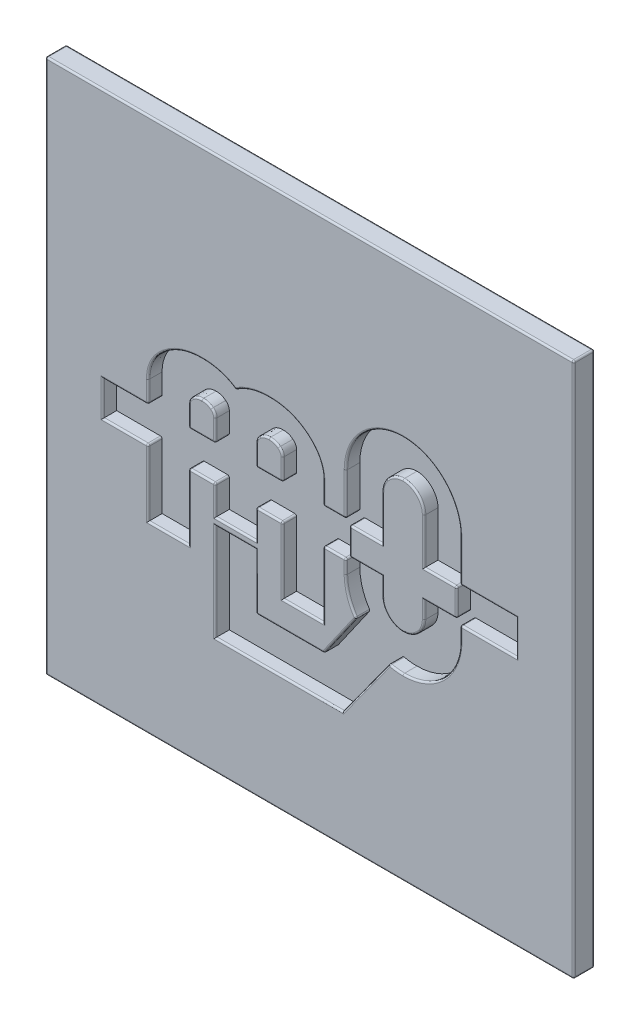
from build123d import *

# Parameters (mm, degrees)
ESBO_O4_W                = 75.8
ESBO_O4_H                = 76.8
RESSALTO_EXTRUS_O6_DEPTH = 1
ESBO_O2_W                = 75.8
ESBO_O2_H                = 76.8
RESSALTO_EXTRUS_O1_DEPTH = 3
FILETE1_R                = 0.25


with BuildPart() as part:
    # Esboço4 → Ressalto-extrusão6 (new body)
    with BuildSketch(Plane.XY):
        with Locations((33.383805964, -31.34946211)):
            Rectangle(ESBO_O4_W, ESBO_O4_H)
    extrude(amount=RESSALTO_EXTRUS_O6_DEPTH)

    # Esboço2 → Ressalto-extrusão1 (add)
    with BuildSketch(Plane.XY):
        with Locations((33.383805964, -31.34946211)):
            Rectangle(ESBO_O2_W, ESBO_O2_H)
        with BuildLine():
            Line((38.602792411, -35.840951316), (38.602792411, -33.838491955))
            Line((38.602792411, -33.838491955), (35.339621204, -33.838491955))
            Line((35.339621204, -33.838491955), (35.339621204, -43.373197244))
            Line((35.339621204, -43.373197244), (29.53003996, -43.373197244))
            Line((29.53003996, -43.373197244), (29.53003996, -33.83853704))
            Line((29.53003996, -33.83853704), (25.700089136, -33.838882375))
            Line((25.700089136, -33.838882375), (25.699216045, -38.027742975))
            Line((25.699216045, -38.027742975), (19.871317632, -38.027742975))
            Line((19.871317632, -38.027742975), (19.870691064, -33.838882374))
            Line((19.870691064, -33.838882374), (16.040555361, -33.838537038))
            Line((16.040555361, -33.838537038), (16.040555361, -43.373197244))
            Line((16.040555361, -43.373197244), (10.230941894, -43.373197244))
            Line((10.230941894, -43.373197244), (10.230941894, -33.838491955))
            Line((10.230941894, -33.838491955), (3.71082044, -33.838491955))
            Line((3.71082044, -33.838491955), (3.71082044, -28.860432264))
            Line((3.71082044, -28.860432264), (10.230941894, -28.860432264))
            Line((10.230941894, -28.860432264), (10.230941894, -25.767762916))
            add(Edge.make_bspline(
                [(12.520125537, -21.186846618), (12.161589327, -21.481361149), (11.478508088, -22.151017985), (10.765077158, -23.243042596), (10.326009571, -24.448263357), (10.230941894, -25.331943998), (10.230941894, -25.767762916)],
                knots=[3.999994529, 3.999994529, 3.999994529, 3.999994529, 4.249995897, 4.499997265, 4.749998632, 5, 5, 5, 5], degree=3))
            add(Edge.make_bspline(
                [(17.966484449, -19.325726975), (17.457089512, -19.325726975), (16.418731118, -19.402059073), (15.004785579, -19.750970723), (13.693531195, -20.3320269), (12.891893247, -20.881537531), (12.520125537, -21.186846618)],
                knots=[3, 3, 3, 3, 3.250001355, 3.50000271, 3.750004065, 4.00000542, 4.00000542, 4.00000542, 4.00000542], degree=3))
            add(Edge.make_bspline(
                [(22.777352151, -20.730420899), (22.435136603, -20.497769563), (21.71308317, -20.08499804), (20.546604604, -19.646084252), (19.306248733, -19.383399999), (18.408088538, -19.325726975), (17.966484449, -19.325726975)],
                knots=[2.068141729, 2.068141729, 2.068141729, 2.068141729, 2.301106297, 2.534070865, 2.767035432, 3, 3, 3, 3], degree=3))
            add(Edge.make_bspline(
                [(27.604143095, -19.325726975), (27.162098632, -19.325726975), (26.263453928, -19.383444504), (25.019999122, -19.646269008), (23.848951729, -20.085148911), (23.122077466, -20.497966794), (22.777352151, -20.730420899)],
                knots=[1, 1, 1, 1, 1.233058408, 1.466116815, 1.699175223, 1.932233631, 1.932233631, 1.932233631, 1.932233631], degree=3))
            add(Edge.make_bspline(
                [(33.0398984, -21.178917863), (32.669738598, -20.874624758), (31.871479625, -20.32757249), (30.563132067, -19.748947369), (29.151234418, -19.401694181), (28.113219244, -19.325726975), (27.604143095, -19.325726975)],
                knots=[3.9919e-05, 3.9919e-05, 3.9919e-05, 3.9919e-05, 0.250029939, 0.500019959, 0.75000998, 1, 1, 1, 1], degree=3))
            add(Edge.make_bspline(
                [(35.339621204, -25.767762916), (35.339621204, -25.331660129), (35.244187559, -24.447688229), (34.803194529, -23.240737978), (34.086701119, -22.146569866), (33.400046511, -21.474453552), (33.0398984, -21.178917863)],
                knots=[22, 22, 22, 22, 22.24999003, 22.49998006, 22.749970091, 22.999960121, 22.999960121, 22.999960121, 22.999960121], degree=3))
            Line((35.339621204, -25.767762916), (35.339621204, -28.860432264))
            Line((35.339621204, -28.860432264), (38.602792411, -28.860432264))
            Line((38.602792411, -28.860432264), (38.602792411, -22.842920896))
            add(Edge.make_bspline(
                [(46.797613273, -14.645489949), (46.246180807, -14.645489949), (45.128374456, -14.76083346), (43.080307896, -15.408787825), (40.869208073, -16.912223198), (39.366010859, -19.123952386), (38.718128317, -21.172814358), (38.602792411, -22.291217691), (38.602792411, -22.842920896)],
                knots=[0, 0, 0, 0, 0.125, 0.25, 0.5, 0.75, 0.875, 1, 1, 1, 1], degree=3))
            add(Edge.make_bspline(
                [(54.99504422, -22.842920896), (54.99504422, -22.291266213), (54.879896849, -21.172953621), (54.232788183, -19.124135909), (52.730639152, -16.912256195), (50.519086668, -15.408719739), (48.469348564, -14.760807883), (47.34979744, -14.645489949), (46.797613273, -14.645489949)],
                knots=[9, 9, 9, 9, 9.125, 9.25, 9.5, 9.75, 9.875, 10, 10, 10, 10], degree=3))
            Line((54.99504422, -22.842920896), (54.99504422, -28.860432264))
            Line((54.99504422, -28.860432264), (63.056791489, -28.860432264))
            Line((63.056791489, -28.860432264), (63.056791489, -33.838491955))
            Line((63.056791489, -33.838491955), (54.99504422, -33.838491955))
            Line((54.99504422, -33.838491955), (54.99504422, -35.840951316))
            add(Edge.make_bspline(
                [(54.778405418, -37.700723526), (54.814396652, -37.550265426), (54.877291352, -37.247758745), (54.945118138, -36.785428618), (54.98593037, -36.317198702), (54.99504422, -35.99928574), (54.99504422, -35.840951316)],
                knots=[12.00085461, 12.00085461, 12.00085461, 12.00085461, 12.250640957, 12.500427305, 12.750213652, 13, 13, 13, 13], degree=3))
            add(Edge.make_bspline(
                [(46.797613273, -44.038414486), (47.272657444, -44.038414486), (48.234123656, -43.953528144), (50.022954031, -43.472675095), (52.019859246, -42.338480082), (53.839600794, -40.314868095), (54.571707331, -38.588043624), (54.778405418, -37.700723526)],
                knots=[11, 11, 11, 11, 11.124982294, 11.249964588, 11.499929176, 11.749893764, 11.999858353, 11.999858353, 11.999858353, 11.999858353], degree=3))
            add(Edge.make_bspline(
                [(44.824204036, -43.795232726), (44.983014121, -43.835039775), (45.302141963, -43.904918132), (45.792159443, -43.981327313), (46.289665386, -44.027859613), (46.62884194, -44.038414486), (46.797613273, -44.038414486)],
                knots=[10.154565866, 10.154565866, 10.154565866, 10.154565866, 10.365924399, 10.577282933, 10.788641466, 11, 11, 11, 11], degree=3))
            Line((44.824204036, -43.795232726), (38.148867116, -53.002999655))
            Line((38.148867116, -53.002999655), (19.871242848, -53.000243488))
            Line((19.871242848, -53.000243488), (19.871242848, -39.094640358))
            Line((19.871242848, -39.094640358), (25.688751016, -39.094640358))
            Line((25.688751016, -39.094640358), (25.688751016, -47.11417514))
            Line((25.688751016, -47.11417514), (35.455669788, -47.11417514))
            Line((35.455669788, -47.11417514), (40.074399539, -40.514566147))
            add(Edge.make_bspline(
                [(38.602792411, -35.840951316), (38.602792411, -36.266635892), (38.670782886, -37.126960153), (38.96176903, -38.340427671), (39.42705098, -39.483596521), (39.842011377, -40.181929217), (40.074399539, -40.514566147)],
                knots=[8, 8, 8, 8, 8.232321709, 8.464643418, 8.696965127, 8.929286836, 8.929286836, 8.929286836, 8.929286836], degree=3))
        make_face(mode=Mode.SUBTRACT)
        with BuildLine():
            Line((43.78038713, -29.360432264), (39.102792411, -29.360432264))
            Line((39.102792411, -29.360432264), (39.102792411, -33.338491955))
            Line((39.102792411, -33.338491955), (43.78038713, -33.338491955))
            Line((43.78038713, -33.338491955), (43.78038713, -35.840951316))
            add(Edge.make_bspline(
                [(43.78038713, -35.840951316), (43.78038713, -35.917513812), (43.783029438, -35.999360925), (43.790956363, -36.075891198)],
                knots=[4, 4, 4, 4, 5, 5, 5, 5], degree=3))
            add(Edge.make_bspline(
                [(43.790956363, -36.075891198), (43.915015963, -37.609590087), (45.240165832, -38.860819768), (46.797613273, -38.860819768)],
                knots=[3, 3, 3, 3, 4, 4, 4, 4], degree=3))
            add(Edge.make_bspline(
                [(46.797613273, -38.860819768), (47.209394476, -38.860819768), (47.605354051, -38.773720262), (47.964353533, -38.615310653)],
                knots=[2, 2, 2, 2, 3, 3, 3, 3], degree=3))
            add(Edge.make_bspline(
                [(47.964353533, -38.615310653), (48.476478007, -38.396224622), (48.917324601, -38.034582832), (49.242006297, -37.585841535)],
                knots=[1, 1, 1, 1, 2, 2, 2, 2], degree=3))
            add(Edge.make_bspline(
                [(49.242006297, -37.585841535), (49.603615864, -37.092180997), (49.817449502, -36.487704623), (49.817449502, -35.840951316)],
                knots=[0, 0, 0, 0, 1, 1, 1, 1], degree=3))
            Line((49.817449502, -35.840951316), (49.817449502, -33.338491955))
            Line((49.817449502, -33.338491955), (54.49504422, -33.338491955))
            Line((54.49504422, -33.338491955), (54.49504422, -29.360432264))
            Line((54.49504422, -29.360432264), (49.817449502, -29.360432264))
            Line((49.817449502, -29.360432264), (49.817449502, -22.842920896))
            add(Edge.make_bspline(
                [(49.817449502, -22.842920896), (49.817449502, -21.208943181), (48.436875604, -19.825726975), (46.797613273, -19.825726975)],
                knots=[5, 5, 5, 5, 6, 6, 6, 6], degree=3))
            add(Edge.make_bspline(
                [(46.797613273, -19.825726975), (45.163603336, -19.825726975), (43.78038713, -21.208943181), (43.78038713, -22.842920896)],
                knots=[4, 4, 4, 4, 5, 5, 5, 5], degree=3))
            Line((43.78038713, -22.842920896), (43.78038713, -29.360432264))
        make_face()
        with BuildLine():
            Line((16.040555361, -25.767762916), (16.040555361, -28.860539673))
            Line((16.040555361, -28.860539673), (19.870703472, -28.861362545))
            Line((19.870703472, -28.861362545), (19.871242847, -25.767722575))
            add(Edge.make_bspline(
                [(19.357259043, -24.750033208), (19.442783619, -24.822366624), (19.610567523, -24.991546185), (19.760039044, -25.229893455), (19.850418745, -25.4780649), (19.871240174, -25.673079731), (19.871242847, -25.767722575)],
                knots=[11.00414162, 11.00414162, 11.00414162, 11.00414162, 11.253097909, 11.502054199, 11.751010488, 11.999966777, 11.999966777, 11.999966777, 11.999966777], degree=3))
            add(Edge.make_bspline(
                [(17.966484449, -24.290607347), (18.100523776, -24.290607347), (18.377295699, -24.310920694), (18.73364105, -24.398560477), (19.059801071, -24.539677966), (19.262971199, -24.675038051), (19.357259043, -24.750033208)],
                knots=[10, 10, 10, 10, 10.248969952, 10.497939903, 10.746909855, 10.995879807, 10.995879807, 10.995879807, 10.995879807], degree=3))
            add(Edge.make_bspline(
                [(16.561927566, -24.758368834), (16.655502032, -24.682099093), (16.857599462, -24.544539251), (17.184713557, -24.400958669), (17.545118814, -24.311448895), (17.829310899, -24.290607347), (17.966484449, -24.290607347)],
                knots=[9.000463177, 9.000463177, 9.000463177, 9.000463177, 9.250347382, 9.500231588, 9.750115794, 10, 10, 10, 10], degree=3))
            add(Edge.make_bspline(
                [(16.040555361, -25.767762916), (16.040555361, -25.67343749), (16.061664386, -25.478769736), (16.153001465, -25.233124542), (16.30414249, -24.997295321), (16.475098867, -24.829631554), (16.561927566, -24.758368834)],
                knots=[8, 8, 8, 8, 8.249883741, 8.499767482, 8.749651223, 8.999534964, 8.999534964, 8.999534964, 8.999534964], degree=3))
        make_face()
        with BuildLine():
            add(Edge.make_bspline(
                [(26.223341059, -24.758363558), (26.135949608, -24.829640273), (25.963591492, -24.997579789), (25.812027948, -25.233202857), (25.720466811, -25.47859441), (25.699324018, -25.673361668), (25.699320251, -25.767706763)],
                knots=[15.000046432, 15.000046432, 15.000046432, 15.000046432, 15.250129866, 15.5002133, 15.750296734, 16.000380169, 16.000380169, 16.000380169, 16.000380169], degree=3))
            Line((25.699320251, -25.767706763), (25.700071847, -28.861362547))
            Line((25.700071847, -28.861362547), (29.53003996, -28.860539678))
            Line((29.53003996, -28.860539678), (29.53003996, -25.767762916))
            add(Edge.make_bspline(
                [(29.53003996, -25.767762916), (29.53003996, -25.673573225), (29.508787662, -25.479613193), (29.416195982, -25.232638043), (29.262121296, -24.993959887), (29.086888444, -24.823018106), (28.998124949, -24.750436423)],
                knots=[17.999963874, 17.999963874, 17.999963874, 17.999963874, 18.249972905, 18.499981937, 18.749990968, 19, 19, 19, 19], degree=3))
            add(Edge.make_bspline(
                [(28.998124949, -24.750436423), (28.906578829, -24.675538515), (28.709127854, -24.541109576), (28.385403368, -24.399644702), (28.026422881, -24.311250743), (27.74147015, -24.290607347), (27.604143095, -24.290607347)],
                knots=[17, 17, 17, 17, 17.250009286, 17.500018572, 17.750027857, 18.000037143, 18.000037143, 18.000037143, 18.000037143], degree=3))
            add(Edge.make_bspline(
                [(27.604143095, -24.290607347), (27.470255875, -24.290607347), (27.193260911, -24.311323254), (26.840002844, -24.400485825), (26.51775606, -24.543642539), (26.316363608, -24.682062228), (26.223341059, -24.758363558)],
                knots=[15.999618536, 15.999618536, 15.999618536, 15.999618536, 16.249713902, 16.499809268, 16.749904634, 17, 17, 17, 17], degree=3))
        make_face()
    extrude(amount=RESSALTO_EXTRUS_O1_DEPTH)

    # Filete1
    filete1_edges = [part.edges().sort_by_distance(p)[0] for p in [
        (10.836256851, -23.211806198, 3),
        (15.075593239, -19.771546034, 3),
        (20.480866608, -19.660076783, 3),
        (25.082563582, -19.661108327, 3),
        (30.489185033, -19.768445504, 3),
        (34.730303712, -23.206612357, 3),
        (35.339621204, -27.31409759, 3),
        (36.971206808, -28.860432264, 3),
        (38.602792411, -25.85167658, 3),
        (41.01013698, -17.054533801, 3),
        (52.5876544, -17.052820484, 3),
        (54.99504422, -25.85167658, 3),
        (59.025917855, -28.860432264, 3),
        (63.056791489, -31.34946211, 3),
        (59.025917855, -33.838491955, 3),
        (54.99504422, -34.839721635, 3),
        (54.941454435, -36.777232639, 3),
        (51.888387364, -42.256296698, 3),
        (45.803417955, -43.977587748, 3),
        (41.486535576, -48.39911619, 3),
        (29.010054982, -53.001621571, 3),
        (19.871242848, -46.047441923, 3),
        (22.779996932, -39.094640358, 3),
        (25.688751016, -43.104407749, 3),
        (30.572210402, -47.11417514, 3),
        (37.765034664, -43.814370643, 3),
        (38.978819444, -38.291007303, 3),
        (38.602792411, -34.839721635, 3),
        (36.971206808, -33.838491955, 3),
        (35.339621204, -38.605844599, 3),
        (32.434830582, -43.373197244, 3),
        (29.53003996, -38.605867142, 3),
        (27.615064548, -33.838709708, 3),
        (25.699652591, -35.933312675, 3),
        (22.785266838, -38.027742975, 3),
        (19.871004348, -35.933312674, 3),
        (17.955623212, -33.838709706, 3),
        (16.040555361, -38.605867141, 3),
        (13.135748627, -43.373197244, 3),
        (10.230941894, -38.605844599, 3),
        (6.970881167, -33.838491955, 3),
        (3.71082044, -31.34946211, 3),
        (6.970881167, -28.860432264, 3),
        (10.230941894, -27.31409759, 3),
        (71.283805964, -31.34946211, 3),
        (33.383805964, 7.05053789, 3),
        (-4.516194036, -31.34946211, 3),
        (33.383805964, -69.74946211, 3),
        (10.230941894, -28.860432264, 2),
        (10.230941894, -33.838491955, 2),
        (16.040555361, -33.838537038, 2),
        (19.870691064, -33.838882374, 2),
        (25.700089136, -33.838882375, 2),
        (29.53003996, -33.83853704, 2),
        (35.339621204, -33.838491955, 2),
        (38.602792411, -33.838491955, 2),
        (40.074399539, -40.514566147, 2),
        (35.455669788, -47.11417514, 2),
        (25.688751016, -47.11417514, 2),
        (44.824204036, -43.795232726, 2),
        (54.778405418, -37.700723526, 2),
        (54.99504422, -33.838491955, 2),
        (54.99504422, -28.860432264, 2),
        (38.602792411, -28.860432264, 2),
        (35.339621204, -28.860432264, 2),
        (33.0398984, -21.178917863, 2),
        (22.777352151, -20.730420899, 2),
        (43.78038713, -34.589721635, 3),
        (43.782704422, -35.958559696, 3),
        (44.759819389, -38.04633527, 3),
        (47.393799284, -38.798944857, 3),
        (48.672839124, -38.187208144, 3),
        (49.669177826, -36.759278337, 3),
        (49.817449502, -34.589721635, 3),
        (52.156246861, -33.338491955, 3),
        (54.49504422, -31.34946211, 3),
        (52.156246861, -29.360432264, 3),
        (49.817449502, -26.10167658, 3),
        (48.921048864, -20.72037705, 3),
        (44.676254934, -20.721573833, 3),
        (43.78038713, -26.10167658, 3),
        (41.44158977, -29.360432264, 3),
        (39.102792411, -31.34946211, 3),
        (41.44158977, -33.338491955, 3),
        (39.102792411, -33.338491955, 2),
        (39.102792411, -29.360432264, 2),
        (54.49504422, -29.360432264, 2),
        (54.49504422, -33.338491955, 2),
        (26.871186619, -24.400729249, 3),
        (25.839573995, -25.201395346, 3),
        (25.699696049, -27.314534655, 3),
        (27.615055904, -28.860951113, 3),
        (29.53003996, -27.314151297, 3),
        (29.386320946, -25.196931764, 3),
        (28.342928698, -24.396539696, 3),
        (29.53003996, -28.860539678, 2),
        (25.700071847, -28.861362547, 2),
        (19.73400294, -25.199825657, 3),
        (18.702580391, -24.398933665, 3),
        (17.22183081, -24.399542732, 3),
        (16.180071976, -25.202021841, 3),
        (16.040555361, -27.314151295, 3),
        (17.955629416, -28.860951109, 3),
        (19.87097316, -27.31454256, 3),
        (19.870703472, -28.861362545, 2),
        (16.040555361, -28.860539673, 2),
        (16.561927566, -24.758368834, 2),
        (19.357259043, -24.750033208, 2),
        (-4.516194036, -31.34946211, 0),
        (33.383805964, -69.74946211, 0),
        (71.283805964, -31.34946211, 0),
        (33.383805964, 7.05053789, 0),
        (71.283805964, 7.05053789, 1.5),
        (71.283805964, -69.74946211, 1.5),
        (-4.516194036, -69.74946211, 1.5),
        (-4.516194036, 7.05053789, 1.5),
    ]]
    fillet(filete1_edges, radius=FILETE1_R)


solid = part.part
